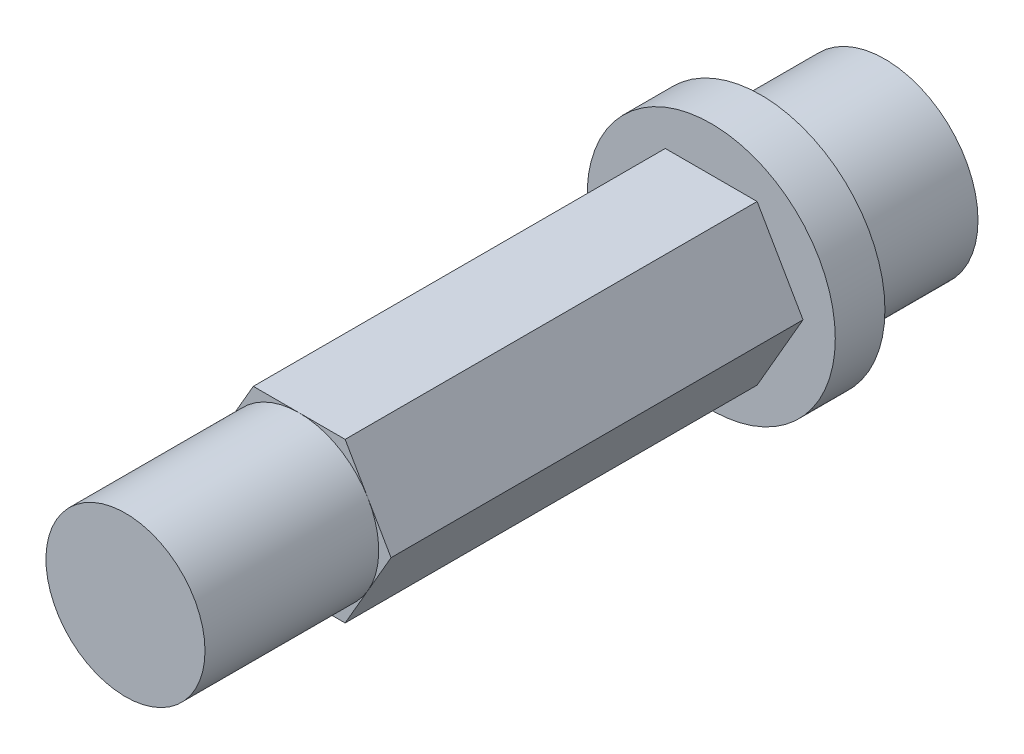
from build123d import *

# Parameters (mm, degrees)
SKETCH1_R           = 3.75
BOSS_EXTRUDE1_DEPTH = 5
SKETCH2_R           = 5
BOSS_EXTRUDE2_DEPTH = 2
BOSS_EXTRUDE3_DEPTH = 16.6
SKETCH4_R           = 3.204293994
BOSS_EXTRUDE4_DEPTH = 7


with BuildPart() as part:
    # Sketch1 → Boss-Extrude1 (new body)
    with BuildSketch(Plane.XY):
        Circle(SKETCH1_R)
    extrude(amount=BOSS_EXTRUDE1_DEPTH)

    # Sketch2 → Boss-Extrude2 (add)
    with BuildSketch(Plane.XY.offset(5)):
        Circle(SKETCH2_R)
    extrude(amount=BOSS_EXTRUDE2_DEPTH)

    # Sketch3 → Boss-Extrude3 (add)
    with BuildSketch(Plane.XY.offset(7)):
        Polygon((3.7, 0), (1.85, 3.204293994), (-1.85, 3.204293994), (-3.7, 0), (-1.85, -3.204293994), (1.85, -3.204293994), align=None)
    extrude(amount=BOSS_EXTRUDE3_DEPTH)

    # Sketch4 → Boss-Extrude4 (add)
    with BuildSketch(Plane.XY.offset(23.6)):
        Circle(SKETCH4_R)
    extrude(amount=BOSS_EXTRUDE4_DEPTH)


solid = part.part
